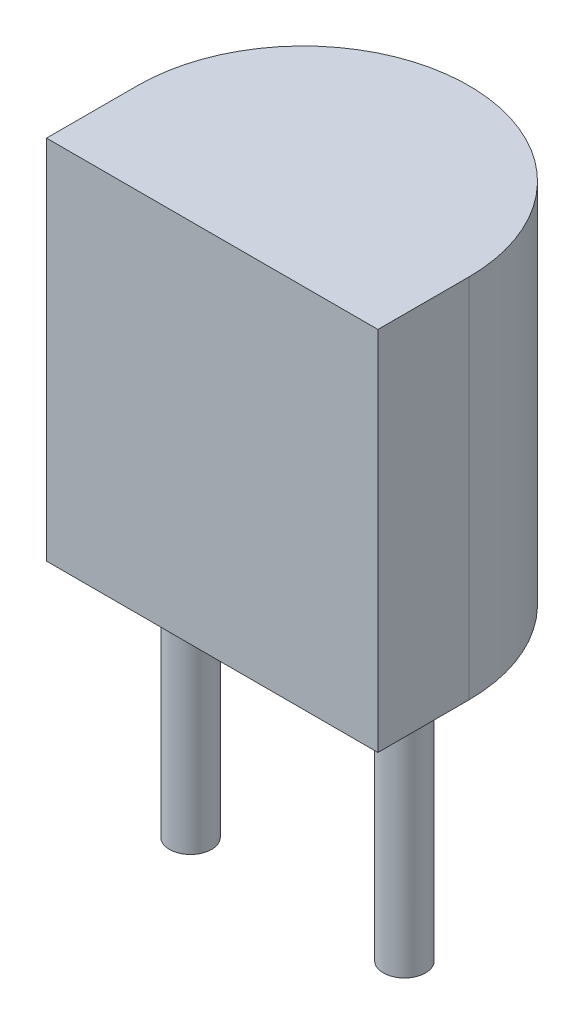
from build123d import *

# Parameters (mm, degrees)
BOSS_EXTRUDE_1_DEPTH = 8.7
SKETCH_2_R           = 0.5
BOSS_EXTRUDE_2_DEPTH = 6


with BuildPart() as part:
    # Sketch 1 → Boss-Extrude 1 (new body)
    with BuildSketch(Plane.ZX.offset(3)):
        with BuildLine():
            Line((-0.13, 1.4), (2.03, 1.4))
            Line((2.03, 1.4), (2.03, -6.47))
            Line((2.03, -6.47), (-0.13, -6.47))
            ThreePointArc((-0.13, -6.47), (-4.065, -2.535), (-0.13, 1.4))
        make_face()
    extrude(amount=BOSS_EXTRUDE_1_DEPTH)

    # Sketch 2 → Boss-Extrude 2 (add)
    with BuildSketch(Plane.XZ.offset(-3)):
        Circle(SKETCH_2_R)
        with Locations((-2.54, -2.54)):
            Circle(SKETCH_2_R)
        with Locations((-5.08, 0)):
            Circle(SKETCH_2_R)
    extrude(amount=BOSS_EXTRUDE_2_DEPTH)


solid = part.part
